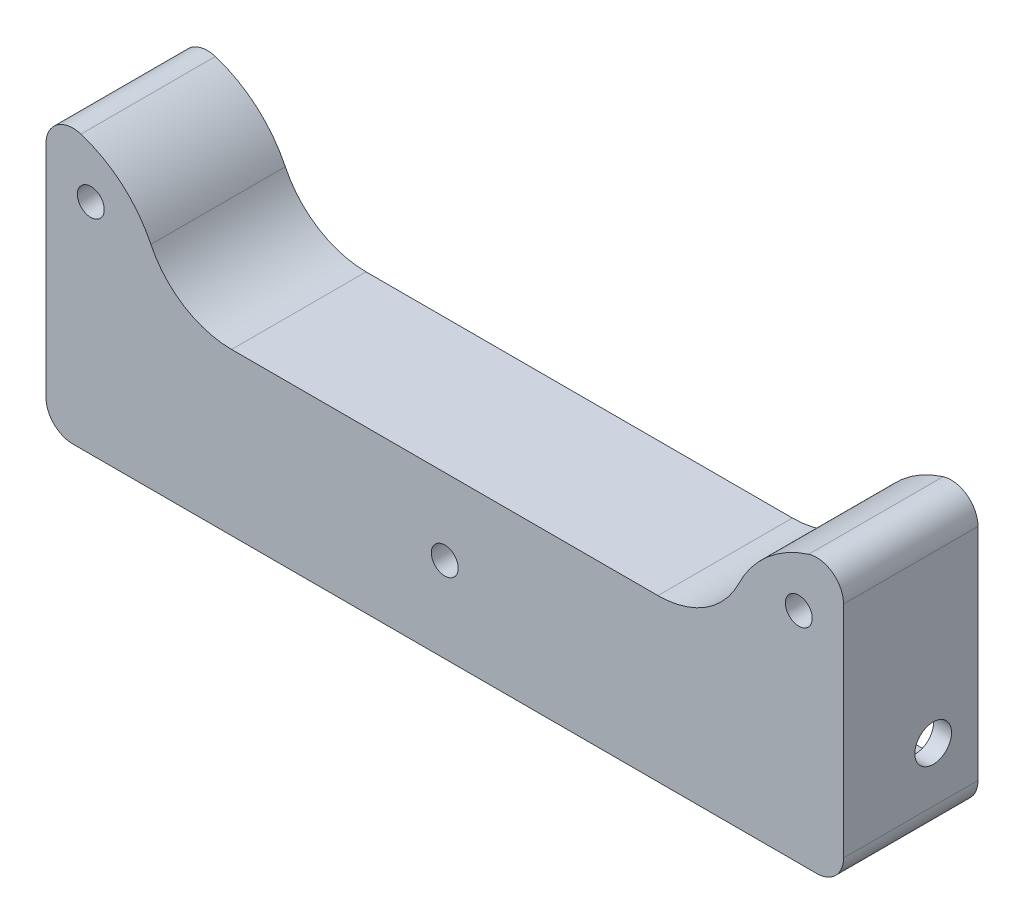
from build123d import *

# Parameters (mm, degrees)
RESSALTO_EXTRUS_O3_DEPTH = 15
CORTE_EXTRUS_O1_DEPTH    = 10.1
ESBO_O3_R                = 1.5
CORTE_EXTRUS_O2_DEPTH    = 16
ESBO_O4_R                = 2.05
CORTE_EXTRUS_O3_DEPTH    = 3
ESBO_O5_R                = 2.05
CORTE_EXTRUS_O4_DEPTH    = 3


with BuildPart() as part:
    # Esboço1 → Ressalto-extrusão3 (new body)
    with BuildSketch(Plane.XY):
        with BuildLine():
            Line((33.436114051, 75.398903013), (-49.563885949, 75.398903013))
            ThreePointArc((-49.563885949, 75.398903013), (-51.685206293, 76.277582669), (-52.563885949, 78.398903013))
            Line((-52.563885949, 78.398903013), (-52.563885949, 93.398903013))
            Line((-52.563885949, 93.398903013), (-52.563885949, 102.938295027))
            ThreePointArc((-52.563885949, 102.938295027), (-51.338709884, 105.356972352), (-48.663885949, 105.800112631))
            ThreePointArc((-48.663885949, 105.800112631), (-44.062022817, 103.23345045), (-40.856925197, 99.051076926))
            ThreePointArc((-40.856925197, 99.051076926), (-37.167666102, 94.929007474), (-31.851570772, 93.398903013))
            Line((-31.851570772, 93.398903013), (-27.063885949, 93.398903013))
            Line((-27.063885949, 93.398903013), (10.936114051, 93.398903013))
            Line((10.936114051, 93.398903013), (15.723798874, 93.398903013))
            ThreePointArc((15.723798874, 93.398903013), (21.039894205, 94.929007474), (24.729153299, 99.051076926))
            ThreePointArc((24.729153299, 99.051076926), (27.934250919, 103.23345045), (32.536114051, 105.800112631))
            ThreePointArc((32.536114051, 105.800112631), (35.210937986, 105.356972352), (36.436114051, 102.938295027))
            Line((36.436114051, 102.938295027), (36.436114051, 93.398903013))
            Line((36.436114051, 93.398903013), (36.436114051, 78.398903013))
            ThreePointArc((36.436114051, 78.398903013), (35.557434395, 76.277582669), (33.436114051, 75.398903013))
        make_face()
    extrude(amount=RESSALTO_EXTRUS_O3_DEPTH)

    # Esboço2 → Corte-extrusão1 (cut)
    with BuildSketch(Plane(origin=(0, 0, 0), x_dir=(-1, 0, 0), z_dir=(0, 0, -1))):
        with BuildLine():
            Line((15.563885949, 89.598903013), (15.563885949, 79.398903013))
            ThreePointArc((15.563885949, 79.398903013), (14.856779168, 77.691796232), (16.563885949, 78.398903013))
            Line((16.563885949, 78.398903013), (49.563885949, 78.398903013))
            ThreePointArc((49.563885949, 78.398903013), (51.27099273, 77.691796232), (50.563885949, 79.398903013))
            Line((50.563885949, 79.398903013), (50.563885949, 89.598903013))
            ThreePointArc((50.563885949, 89.598903013), (51.27099273, 91.306009794), (49.563885949, 90.598903013))
            Line((49.563885949, 90.598903013), (16.563885949, 90.598903013))
            ThreePointArc((16.563885949, 90.598903013), (14.856779168, 91.306009794), (15.563885949, 89.598903013))
        make_face()
        with BuildLine():
            Line((-33.436114051, 90.598903013), (-0.436114051, 90.598903013))
            ThreePointArc((-0.436114051, 90.598903013), (1.27099273, 91.306009794), (0.563885949, 89.598903013))
            Line((0.563885949, 89.598903013), (0.563885949, 79.398903013))
            ThreePointArc((0.563885949, 79.398903013), (1.27099273, 77.691796232), (-0.436114051, 78.398903013))
            Line((-0.436114051, 78.398903013), (-33.436114051, 78.398903013))
            ThreePointArc((-33.436114051, 78.398903013), (-35.143220832, 77.691796232), (-34.436114051, 79.398903013))
            Line((-34.436114051, 79.398903013), (-34.436114051, 89.598903013))
            ThreePointArc((-34.436114051, 89.598903013), (-35.143220832, 91.306009794), (-33.436114051, 90.598903013))
        make_face()
    extrude(amount=-CORTE_EXTRUS_O1_DEPTH, mode=Mode.SUBTRACT)

    # Esboço3 → Corte-extrusão2 (cut, through all)
    with BuildSketch(Plane(origin=(0, 0, 0), x_dir=(-1, 0, 0), z_dir=(0, 0, -1))):
        with Locations((-31.436114051, 99.800112631)):
            Circle(ESBO_O3_R)
        with Locations((47.563885949, 99.800112631)):
            Circle(ESBO_O3_R)
        with Locations((8.063885949, 84.898903013)):
            Circle(ESBO_O3_R)
    extrude(amount=-CORTE_EXTRUS_O2_DEPTH, mode=Mode.SUBTRACT)

    # Esboço4 → Corte-extrusão3 (cut, through all)
    with BuildSketch(Plane.ZY.offset(-34.436114051)):
        with Locations((5, 84.498903013)):
            Circle(ESBO_O4_R)
    extrude(amount=-CORTE_EXTRUS_O3_DEPTH, mode=Mode.SUBTRACT)

    # Esboço5 → Corte-extrusão4 (cut, through all)
    with BuildSketch(Plane(origin=(-50.563885949, 0, 0), x_dir=(0, 0, -1), z_dir=(1, 0, 0))):
        with Locations((-5, 84.498903013)):
            Circle(ESBO_O5_R)
    extrude(amount=-CORTE_EXTRUS_O4_DEPTH, mode=Mode.SUBTRACT)


solid = part.part
